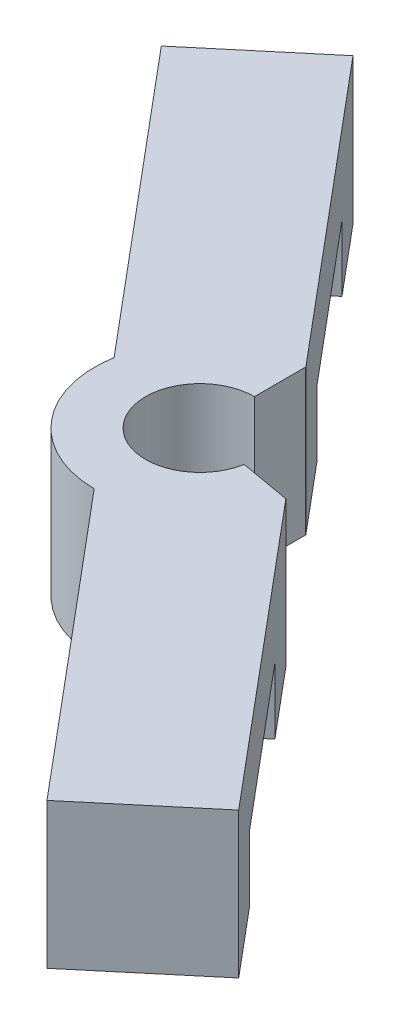
from build123d import *

# Parameters (mm, degrees)
BOSS_EXTRUDE2_DEPTH = 8.55
SKETCH2_W           = 12
SKETCH2_H           = 3.872399236
CUT_EXTRUDE1_DEPTH  = 10


with BuildPart() as part:
    # Sketch1 → Boss-Extrude2 (new body)
    with BuildSketch(Plane(origin=(0, 0, 0), x_dir=(1, 0, 0), z_dir=(0, 1, 0))):
        with BuildLine():
            Line((0, 3.2), (0, 6.2))
            ThreePointArc((0, 6.2), (0.009618254, 6.199992539), (0.019236485, 6.199970158))
            Line((0.019236485, 6.199970158), (-14.46008445, 23.455752899))
            Line((-14.46008445, 23.455752899), (-20.588439995, 18.313452022))
            Line((-20.588439995, 18.313452022), (-6.10911906, 1.05766928))
            ThreePointArc((-6.10911906, 1.05766928), (-4.749475547, -3.98528318), (-0.019236485, -6.199970158))
            Line((-0.019236485, -6.199970158), (14.46008445, -23.455752899))
            Line((14.46008445, -23.455752899), (20.588439995, -18.313452022))
            Line((20.588439995, -18.313452022), (6.10911906, -1.05766928))
            ThreePointArc((6.10911906, -1.05766928), (6.107470914, -1.067145275), (6.105808069, -1.076618702))
            Line((6.105808069, -1.076618702), (3.15138481, -0.555674169))
            ThreePointArc((3.15138481, -0.555674169), (-2.451342218, -2.056920351), (0, 3.2))
        make_face()
    extrude(amount=BOSS_EXTRUDE2_DEPTH)

    # Sketch2 → Cut-Extrude1 (cut)
    with BuildSketch(Plane(origin=(-3.064177772, 0, 2.571150439), x_dir=(0.64278761, 0, 0.766044443), z_dir=(-0.766044443, 0, 0.64278761))):
        with Locations((-16, 1.936199618)):
            Rectangle(SKETCH2_W, SKETCH2_H)
        with Locations((16, 1.936199618)):
            Rectangle(SKETCH2_W, SKETCH2_H)
    extrude(amount=-CUT_EXTRUDE1_DEPTH, mode=Mode.SUBTRACT)


solid = part.part
